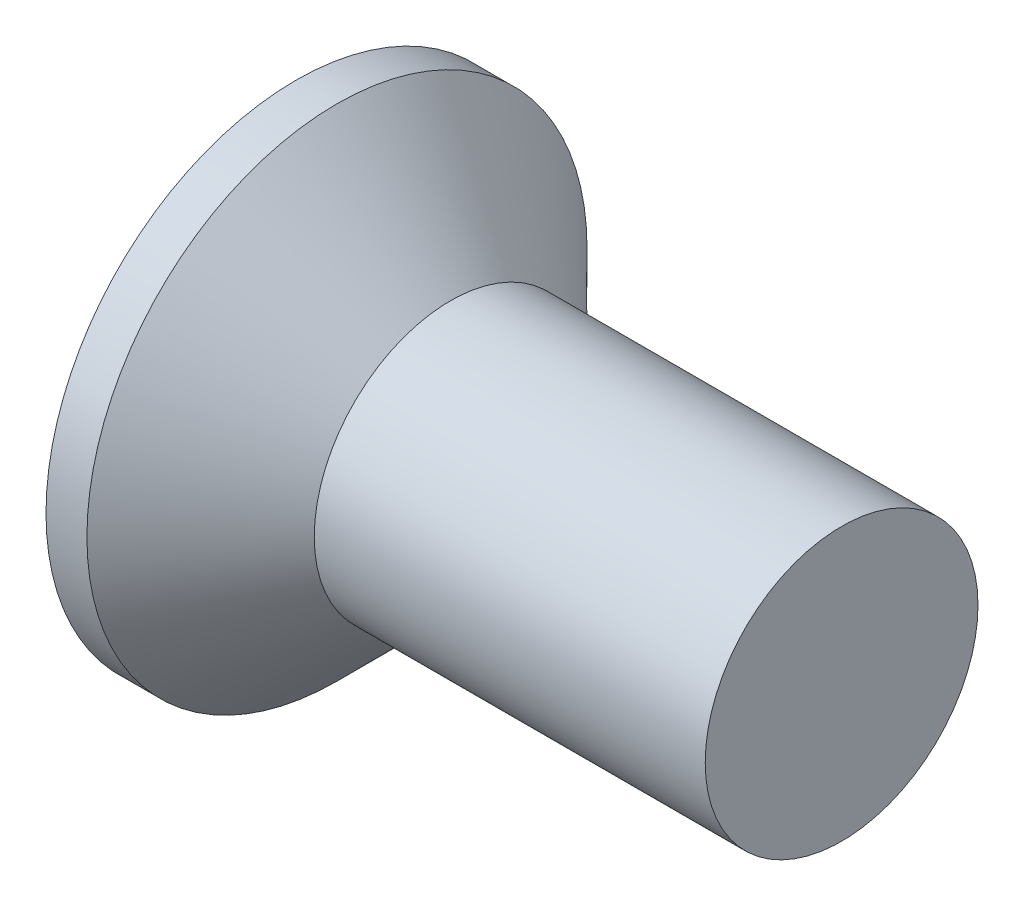
from build123d import *

# Parameters (mm, degrees)
SKETCH3_W         = 0.79
SKETCH3_H         = 3.1
SKETCH4_W         = 0.395
SKETCH4_H         = 0.395
CIRPATTERN1_COUNT = 2
CIRPATTERN1_ANGLE = 90


with BuildPart() as part:
    # BodySke → Base-Revolve (revolve)
    with BuildSketch(Plane.XY):
        Polygon((0, 0), (0, 2.75), (0.45, 2.75), (1.7, 1.5), (6, 1.5), (6, 0), align=None)
    revolve(axis=Axis((-6.35, 0, 0), (1, 0, 0)))

    # Sketch3 → Cross section 0
    with BuildSketch(Plane.ZY):
        Rectangle(SKETCH3_W, SKETCH3_H)
    # Sketch4 → Cross section 1
    with BuildSketch(Plane.ZY.offset(-2.08)):
        Rectangle(SKETCH4_W, SKETCH4_H)
    cross = loft(mode=Mode.SUBTRACT)

    # CirPattern1: Cross ×2 about axis
    cirpattern1_axis = Axis((0, 0, 0), (1, 0, 0))
    for i in range(1, CIRPATTERN1_COUNT):
        add(cross.rotate(cirpattern1_axis, i * CIRPATTERN1_ANGLE / (CIRPATTERN1_COUNT - 1)), mode=Mode.SUBTRACT)


solid = part.part
